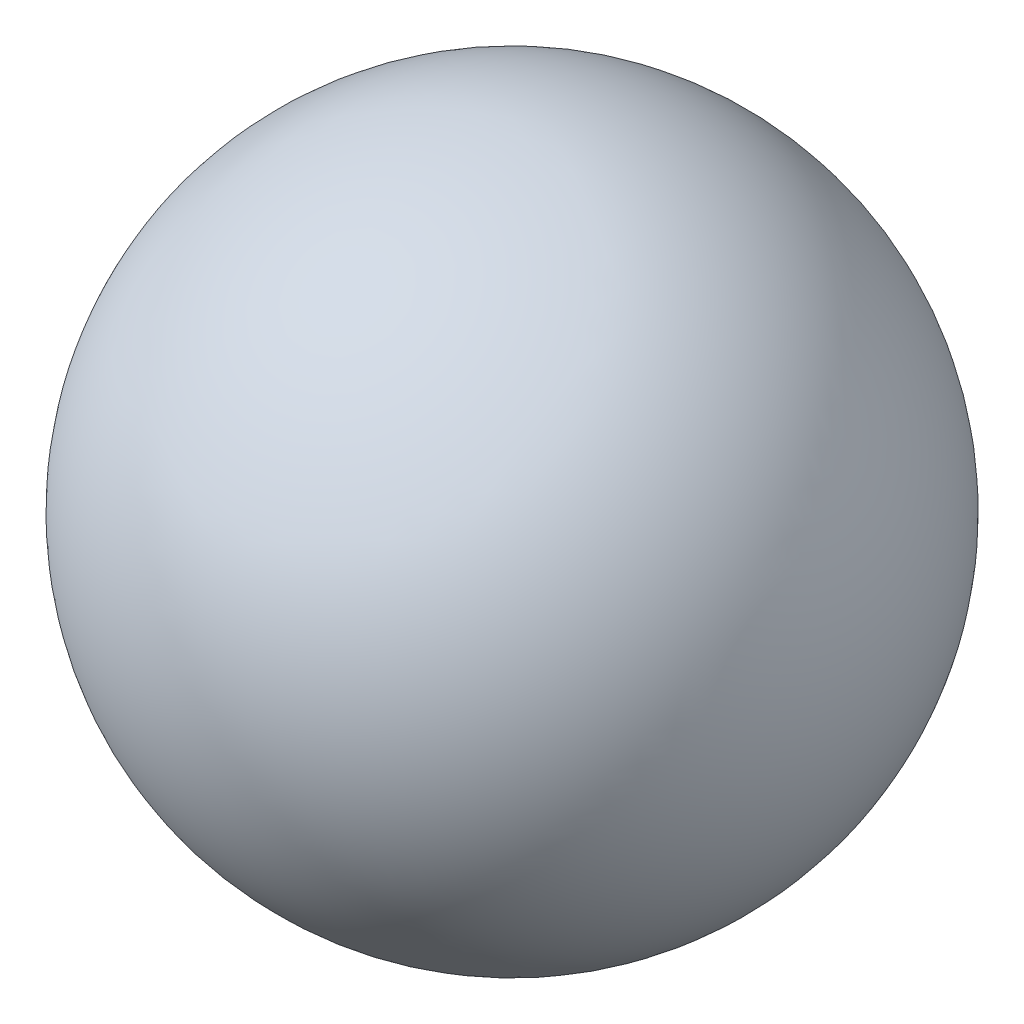
from build123d import *


with BuildPart() as part:
    # Sketch1 → Revolve1 (revolve)
    with BuildSketch(Plane.XY):
        with BuildLine():
            Line((3.492, 4.76), (1.508, 4.76))
            ThreePointArc((1.508, 4.76), (2.5, 5.752), (3.492, 4.76))
        make_face()
    revolve(axis=Axis((3.492, 4.76, 0), (-1, 0, 0)))


solid = part.part
